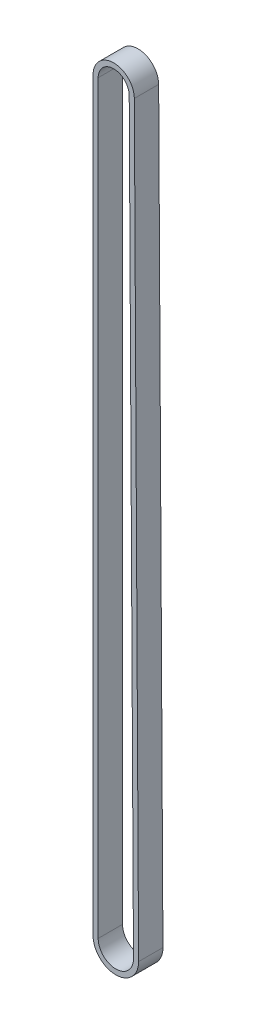
from build123d import *

# Parameters (mm, degrees)
BOSS_EXTRUDE1_DEPTH = 6.2


with BuildPart() as part:
    # Sketch1 → Boss-Extrude1 (new body)
    with BuildSketch(Plane.XY):
        with BuildLine():
            Line((324.756453181, -302.445926457), (324.756052939, -112.552626659))
            ThreePointArc((324.756052939, -112.552626659), (329.995960151, -107.297637015), (335.265966789, -112.522440722))
            Line((335.265966789, -112.522440722), (336.356357561, -302.412609916))
            ThreePointArc((336.356357561, -302.412609916), (330.57311152, -308.245890309), (324.756453181, -302.445926457))
        make_face()
        with BuildLine():
            Line((326.056453181, -302.445923717), (326.056052939, -112.552623919))
            ThreePointArc((326.056052939, -112.552623919), (329.999693916, -108.597631653), (333.965988221, -112.529905483))
            Line((333.965988221, -112.529905483), (335.056378993, -302.420074676))
            ThreePointArc((335.056378993, -302.420074676), (330.569377754, -306.945895671), (326.056453181, -302.445923717))
        make_face(mode=Mode.SUBTRACT)
    extrude(amount=-BOSS_EXTRUDE1_DEPTH)


solid = part.part
